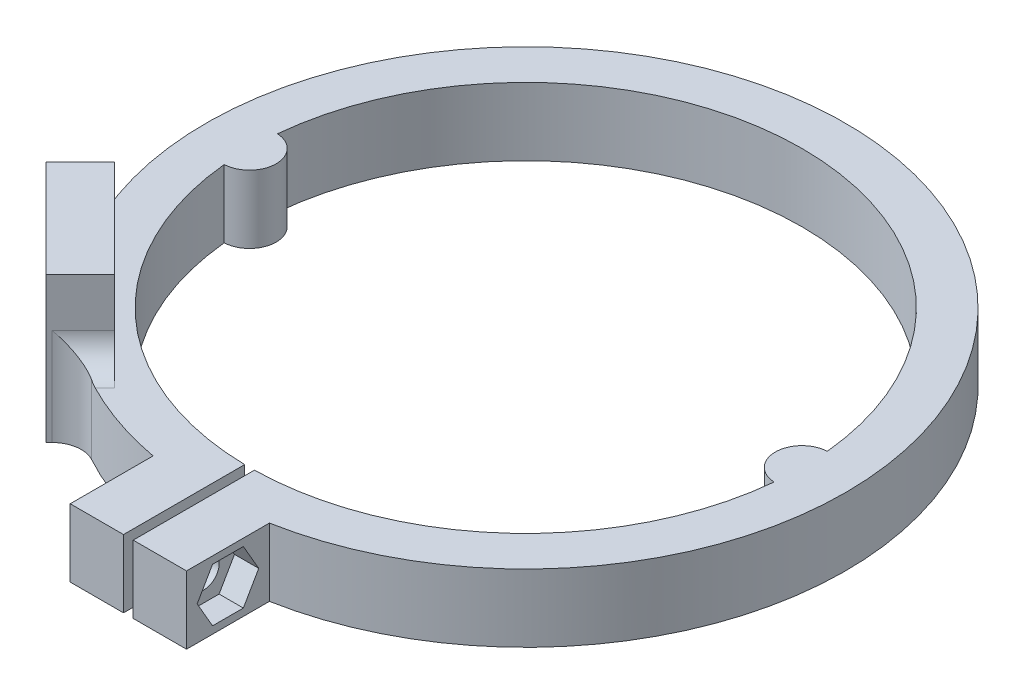
from build123d import *

# Parameters (mm, degrees)
SKETCH1_R           = 33
SKETCH1_R_2         = 28.5
BOSS_EXTRUDE1_DEPTH = 7
SKETCH3_W           = 12
SKETCH3_H           = 9.352768828
BOSS_EXTRUDE2_DEPTH = 7
SKETCH4_R           = 3
CUT_EXTRUDE2_DEPTH  = 3
SKETCH5_R           = 1.6
CUT_EXTRUDE3_DEPTH  = 37
CUT_EXTRUDE4_DEPTH  = 2.5
SKETCH2_W           = 1
SKETCH2_H           = 30
CUT_EXTRUDE1_DEPTH  = 8
SKETCH7_R           = 2.75
BOSS_EXTRUDE3_DEPTH = 7
BOSS_EXTRUDE4_DEPTH = 15
SKETCH9_R           = 1.6
CUT_EXTRUDE5_DEPTH  = 82.669047558
CUT_EXTRUDE6_DEPTH  = 5
FILLET1_R           = 3


with BuildPart() as part:
    # Sketch1 → Boss-Extrude1 (new body)
    with BuildSketch(Plane(origin=(0, 0, 0), x_dir=(1, 0, 0), z_dir=(0, 1, 0))):
        Circle(SKETCH1_R)
        Circle(SKETCH1_R_2, mode=Mode.SUBTRACT)
    extrude(amount=BOSS_EXTRUDE1_DEPTH)

    # Sketch3 → Boss-Extrude2 (add)
    with BuildSketch(Plane(origin=(0, 7, 0), x_dir=(1, 0, 0), z_dir=(0, 1, 0))):
        with Locations((0, -36.323615586)):
            Rectangle(SKETCH3_W, SKETCH3_H)
    extrude(amount=-BOSS_EXTRUDE2_DEPTH)

    # Sketch4 → Cut-Extrude2 (cut)
    with BuildSketch(Plane.ZY.offset(6)):
        with Locations((36.72498074, 3.5)):
            Circle(SKETCH4_R)
    extrude(amount=-CUT_EXTRUDE2_DEPTH, mode=Mode.SUBTRACT)

    # Sketch5 → Cut-Extrude3 (cut, through all)
    with BuildSketch(Plane.ZY.offset(3)):
        with Locations((36.72498074, 3.5)):
            Circle(SKETCH5_R)
    extrude(amount=-CUT_EXTRUDE3_DEPTH, mode=Mode.SUBTRACT)

    # Sketch6 → Cut-Extrude4 (cut)
    with BuildSketch(Plane(origin=(6, 0, 0), x_dir=(0, 0, -1), z_dir=(1, 0, 0))):
        Polygon((-35.137267499, 0.75), (-33.549554259, 3.5), (-35.137267499, 6.25), (-38.31269398, 6.25), (-39.90040722, 3.5), (-38.31269398, 0.75), align=None)
    extrude(amount=-CUT_EXTRUDE4_DEPTH, mode=Mode.SUBTRACT)

    # Sketch2 → Cut-Extrude1 (cut, through all)
    with BuildSketch(Plane(origin=(0, 7, 0), x_dir=(1, 0, 0), z_dir=(0, 1, 0))):
        with Locations((0, -32.66005016)):
            Rectangle(SKETCH2_W, SKETCH2_H)
    extrude(amount=-CUT_EXTRUDE1_DEPTH, mode=Mode.SUBTRACT)

    # Sketch7 → Boss-Extrude3 (add)
    with BuildSketch(Plane(origin=(0, 7, 0), x_dir=(1, 0, 0), z_dir=(0, 1, 0))):
        with Locations((-28.5, 0)):
            Circle(SKETCH7_R)
        with Locations((28.5, 0)):
            Circle(SKETCH7_R)
    extrude(amount=-BOSS_EXTRUDE3_DEPTH)

    # Sketch8 → Boss-Extrude4 (add)
    with BuildSketch(Plane(origin=(0, 0, 0), x_dir=(1, 0, 0), z_dir=(0, 1, 0))):
        Polygon((-26.242146863, -16.184260008), (-16.184260008, -26.242146863), (-19.719793914, -29.777680769), (-29.777680769, -19.719793914), align=None)
    extrude(amount=BOSS_EXTRUDE4_DEPTH)

    # Sketch9 → Cut-Extrude5 (cut, through all)
    with BuildSketch(Plane(origin=(-24.748737342, 0, 24.748737342), x_dir=(0.707106781, 0, 0.707106781), z_dir=(-0.707106781, 0, 0.707106781))):
        with Locations((-3.556, 11)):
            Circle(SKETCH9_R)
        with Locations((3.556, 11)):
            Circle(SKETCH9_R)
    extrude(amount=-CUT_EXTRUDE5_DEPTH, mode=Mode.SUBTRACT)

    # Sketch10 → Cut-Extrude6 (cut)
    with BuildSketch(Plane(origin=(-22.627416998, 0, 22.627416998), x_dir=(0.707106781, 0, 0.707106781), z_dir=(-0.707106781, 0, 0.707106781))):
        Polygon((-0.380573519, 11), (-1.96828676, 13.75), (-5.14371324, 13.75), (-6.731426481, 11), (-5.14371324, 8.25), (-1.96828676, 8.25), align=None)
        Polygon((0.380573519, 11), (1.96828676, 8.25), (5.14371324, 8.25), (6.731426481, 11), (5.14371324, 13.75), (1.96828676, 13.75), align=None)
    extrude(amount=-CUT_EXTRUDE6_DEPTH, mode=Mode.SUBTRACT)

    # Fillet1
    fillet1_edges = [part.edges().sort_by_distance(p)[0] for p in [
        (-17.757230626, 3.5, 27.815117481),
        (-27.815117481, 3.5, 17.757230626),
        (-27.028632172, 7, 16.970745317),
        (-16.970745317, 7, 27.028632172),
    ]]
    fillet(fillet1_edges, radius=FILLET1_R)


solid = part.part
